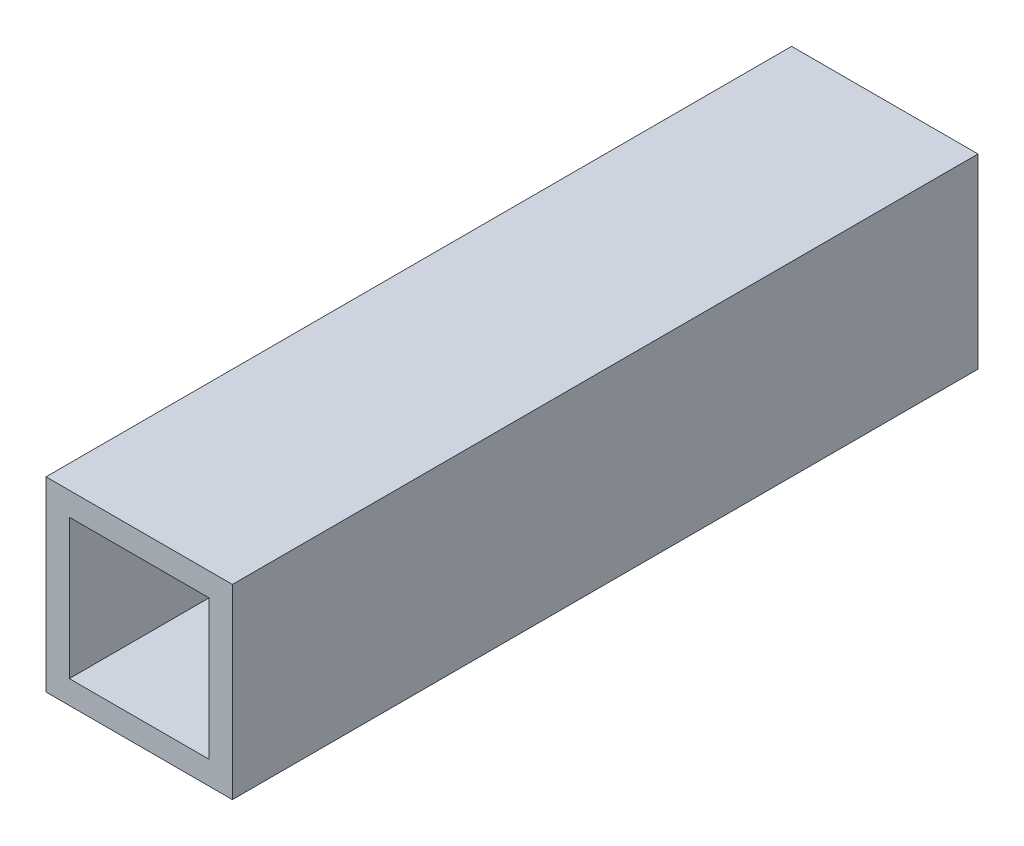
from build123d import *

# Parameters (mm, degrees)
SKETCH1_W           = 25.4
SKETCH1_H           = 25.4
SKETCH1_W_2         = 19.05
SKETCH1_H_2         = 19.05
BOSS_EXTRUDE1_DEPTH = 101.6


with BuildPart() as part:
    # Sketch1 → Boss-Extrude1 (new body)
    with BuildSketch(Plane.XY):
        Rectangle(SKETCH1_W, SKETCH1_H)
        Rectangle(SKETCH1_W_2, SKETCH1_H_2, mode=Mode.SUBTRACT)
    extrude(amount=BOSS_EXTRUDE1_DEPTH)


solid = part.part
